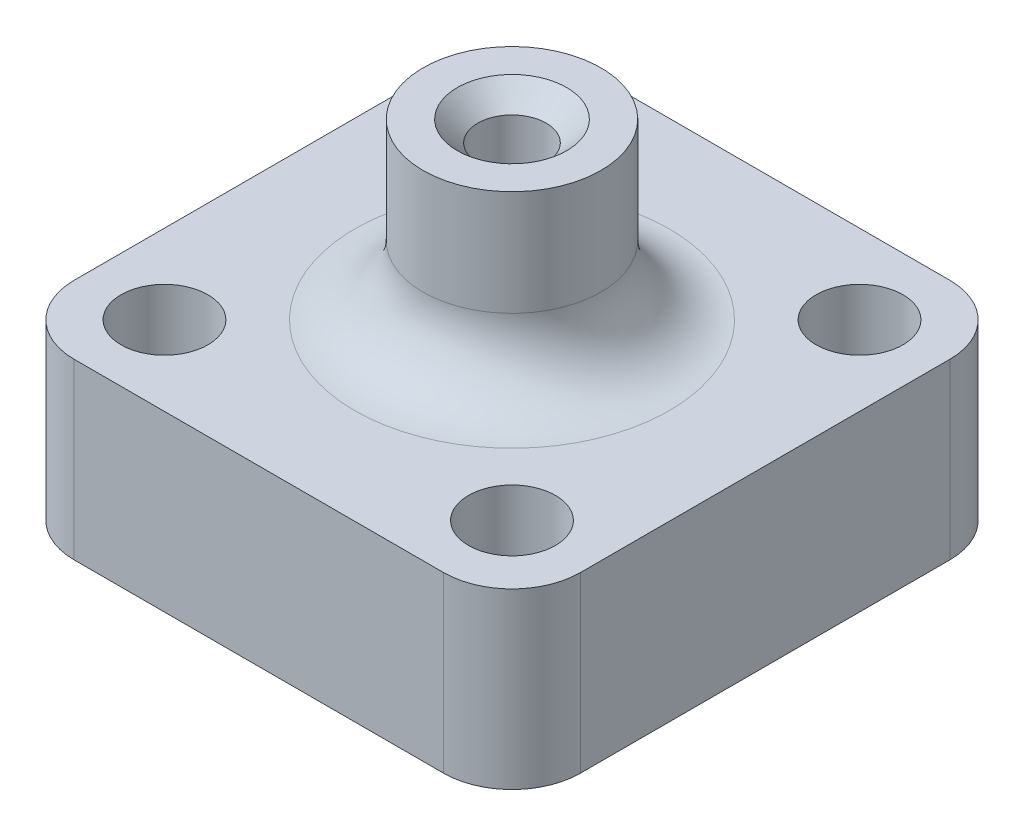
from build123d import *

# Parameters (mm, degrees)
SKETCH1_W           = 37
SKETCH1_H           = 37
SKETCH1_R           = 2.5
SKETCH1_R_2         = 3.175
BOSS_EXTRUDE1_DEPTH = 12.7
SKETCH2_R           = 6.5
SKETCH2_R_2         = 2.5
BOSS_EXTRUDE2_DEPTH = 12.7
FILLET1_R           = 5
CHAMFER1_SIZE       = 1.5


with BuildPart() as part:
    # Sketch1 → Boss-Extrude1 (new body)
    with BuildSketch(Plane(origin=(0, 0, 0), x_dir=(1, 0, 0), z_dir=(0, 1, 0))):
        Rectangle(SKETCH1_W, SKETCH1_H)
        Circle(SKETCH1_R, mode=Mode.SUBTRACT)
        with Locations((-12.7, -12.7)):
            Circle(SKETCH1_R_2, mode=Mode.SUBTRACT)
        with Locations((12.7, -12.7)):
            Circle(SKETCH1_R_2, mode=Mode.SUBTRACT)
        with Locations((12.7, 12.7)):
            Circle(SKETCH1_R_2, mode=Mode.SUBTRACT)
        with Locations((-12.7, 12.7)):
            Circle(SKETCH1_R_2, mode=Mode.SUBTRACT)
    extrude(amount=BOSS_EXTRUDE1_DEPTH)

    # Sketch2 → Boss-Extrude2 (add)
    with BuildSketch(Plane(origin=(0, 12.7, 0), x_dir=(1, 0, 0), z_dir=(0, 1, 0))):
        Circle(SKETCH2_R)
        Circle(SKETCH2_R_2, mode=Mode.SUBTRACT)
    extrude(amount=BOSS_EXTRUDE2_DEPTH)

    # Fillet1
    fillet1_edges = [part.edges().sort_by_distance(p)[0] for p in [
        (-6.5, 12.7, 0),
        (18.5, 6.35, 18.5),
        (-18.5, 6.35, 18.5),
        (-18.5, 6.35, -18.5),
        (18.5, 6.35, -18.5),
    ]]
    fillet(fillet1_edges, radius=FILLET1_R)

    # Chamfer1
    chamfer1_edges = [part.edges().sort_by_distance(p)[0] for p in [
        (-2.5, 25.4, 0),
    ]]
    chamfer(chamfer1_edges, length=CHAMFER1_SIZE)


solid = part.part
